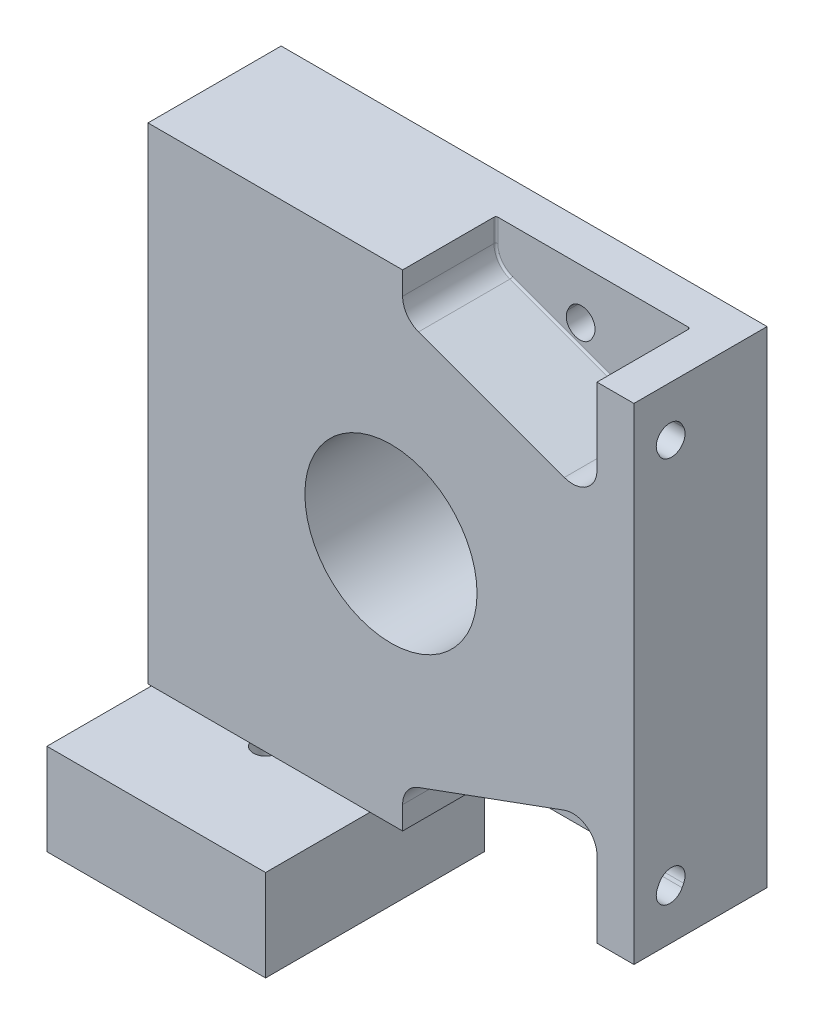
from build123d import *

# Parameters (mm, degrees)
SKETCH2_W                        = 127
SKETCH2_H                        = 127
HOUSING_DEPTH                    = 39.5
SKETCH4_OUTSIDE_W                = 165.78
SKETCH4_OUTSIDE_H                = 165.78
SKETCH4_OUTSIDE_R                = 45.974
CUT_EXTRUDE2_DEPTH               = 4.698
MOUNTING_POCKETS_DEPTH           = 24.384
ENG_METRIC_SLOT_VERTICAL_REACH   = 129
ENG_METRIC_SLOT_HORIZONTAL_DEPTH = 40.5
FILLET3_R                        = 0.508
SKETCH213_W                      = 57.15
SKETCH213_H                      = 57.15
EXTRUDE1_DEPTH                   = 26.924
SKETCH214_R                      = 23.8125
CUT_EXTRUDE3_DEPTH               = 5
SKETCH215_R                      = 3.175
CUT_EXTRUDE4_DEPTH               = 21.924
CUT_EXTRUDE5_REACH               = 131.159
SKETCH216_W                      = 42.545
SKETCH216_H                      = 3.048
F_8_32_TAPPED_HOLE1_D            = 3.4544
F_8_32_TAPPED_HOLE1_DEPTH        = 10.7086
F_8_32_TAPPED_HOLE1_TIP          = 1.037806461
SKETCH241_R                      = 45.974
CUT_EXTRUDE7_DEPTH               = 4.698
SKETCH3_R                        = 22.5
CUT_EXTRUDE8_DEPTH               = 49.26


with BuildPart() as part:
    # Sketch2 → HOUSING (new body)
    with BuildSketch(Plane.XY):
        Rectangle(SKETCH2_W, SKETCH2_H)
    extrude(amount=HOUSING_DEPTH)

    # Sketch4 outside → Cut-Extrude2 (cut)
    with BuildSketch(Plane.XY.offset(39.5)):
        Rectangle(SKETCH4_OUTSIDE_W, SKETCH4_OUTSIDE_H)
        Circle(SKETCH4_OUTSIDE_R, mode=Mode.SUBTRACT)
    extrude(amount=-CUT_EXTRUDE2_DEPTH, mode=Mode.SUBTRACT)

    # Sketch8 → MOUNTING POCKETS (cut)
    with BuildSketch(Plane.XY.offset(34.802)):
        with BuildLine():
            Line((3.048, -63.5), (3.048, -57.528018122))
            ThreePointArc((3.048, -57.528018122), (4.194729662, -53.888172274), (7.220748912, -51.562946647))
            Line((7.220748912, -51.562946647), (45.320748912, -37.656446647))
            ThreePointArc((45.320748912, -37.656446647), (51.137845848, -38.418247784), (53.848, -43.621518122))
            Line((53.848, -43.621518122), (53.848, -63.5))
            Line((53.848, -63.5), (3.048, -63.5))
        make_face()
        with BuildLine():
            Line((3.048, 63.5), (53.848, 63.5))
            Line((53.848, 63.5), (53.848, 43.621518122))
            ThreePointArc((53.848, 43.621518122), (51.137845848, 38.418247784), (45.320748912, 37.656446647))
            Line((45.320748912, 37.656446647), (7.220748912, 51.562946647))
            ThreePointArc((7.220748912, 51.562946647), (4.194729662, 53.888172274), (3.048, 57.528018122))
            Line((3.048, 57.528018122), (3.048, 63.5))
        make_face()
    extrude(amount=-MOUNTING_POCKETS_DEPTH, mode=Mode.SUBTRACT)

    # Sketch21 → ENG_METRIC SLOT VERTICAL (cut, up to next)
    with BuildSketch(Plane(origin=(63.5, -23.646142673, 1.166551585), x_dir=(0, 0, -1), z_dir=(1, 0, 0)), mode=Mode.PRIVATE) as eng_metric_slot_vertical_sk1:
        with BuildLine():
            Line((-20.641506099, 75.242113831), (-21.041506099, 76.042113831))
            ThreePointArc((-21.041506099, 76.042113831), (-25.829419573, 77.63808499), (-27.425390732, 72.850171515))
            Line((-27.425390732, 72.850171515), (-27.025390732, 72.050171515))
            ThreePointArc((-27.025390732, 72.050171515), (-22.237477257, 70.454200357), (-20.641506099, 75.242113831))
        make_face()
    eng_metric_slot_vertical_tool1 = extrude(eng_metric_slot_vertical_sk1.sketch, amount=-ENG_METRIC_SLOT_VERTICAL_REACH, mode=Mode.PRIVATE) & part.part
    add(eng_metric_slot_vertical_tool1.solids().sort_by_distance((63.5, 50.4, 25.2))[0], mode=Mode.SUBTRACT)
    # Sketch21 → ENG_METRIC SLOT VERTICAL (cut, up to next)
    with BuildSketch(Plane(origin=(63.5, -23.646142673, 1.166551585), x_dir=(0, 0, -1), z_dir=(1, 0, 0)), mode=Mode.PRIVATE) as eng_metric_slot_vertical_sk2:
        with BuildLine():
            Line((-27.025390732, -24.757886169), (-27.425390732, -25.557886169))
            ThreePointArc((-27.425390732, -25.557886169), (-25.829419573, -30.345799643), (-21.041506099, -28.749828485))
            Line((-21.041506099, -28.749828485), (-20.641506099, -27.949828485))
            ThreePointArc((-20.641506099, -27.949828485), (-22.237477257, -23.16191501), (-27.025390732, -24.757886169))
        make_face()
    eng_metric_slot_vertical_tool2 = extrude(eng_metric_slot_vertical_sk2.sketch, amount=-ENG_METRIC_SLOT_VERTICAL_REACH, mode=Mode.PRIVATE) & part.part
    add(eng_metric_slot_vertical_tool2.solids().sort_by_distance((63.5, -50.4, 25.2))[0], mode=Mode.SUBTRACT)

    # Sketch212 → ENG_METRIC SLOT HORIZONTAL (cut, through all)
    with BuildSketch(Plane(origin=(34.062086582, -104.655987826, 0), x_dir=(-1, 0, 0), z_dir=(0, 0, -1))):
        with BuildLine():
            Line((12.254028899, 156.251958985), (11.854028899, 157.051958985))
            ThreePointArc((11.854028899, 157.051958985), (7.066115424, 158.647930143), (5.470144266, 153.860016668))
            Line((5.470144266, 153.860016668), (5.870144266, 153.060016668))
            ThreePointArc((5.870144266, 153.060016668), (10.658057741, 151.46404551), (12.254028899, 156.251958985))
        make_face()
        with BuildLine():
            Line((5.870144266, 56.251958985), (5.470144266, 55.451958985))
            ThreePointArc((5.470144266, 55.451958985), (7.066115424, 50.66404551), (11.854028899, 52.260016668))
            Line((11.854028899, 52.260016668), (12.254028899, 53.060016668))
            ThreePointArc((12.254028899, 53.060016668), (10.658057741, 57.847930143), (5.870144266, 56.251958985))
        make_face()
    extrude(amount=-ENG_METRIC_SLOT_HORIZONTAL_DEPTH, mode=Mode.SUBTRACT)

    # Fillet3
    fillet3_edges = [part.edges().sort_by_distance(p)[0] for p in [
        (3.048, -60.514009061, 10.418),
        (4.194729662, -53.888172274, 10.418),
        (26.270748912, -44.609696647, 10.418),
        (51.137845848, -38.418247784, 10.418),
        (53.848, -53.560759061, 10.418),
        (51.137845848, 38.418247784, 10.418),
        (26.270748912, 44.609696647, 10.418),
        (4.194729662, 53.888172274, 10.418),
        (3.048, 60.514009061, 10.418),
        (53.848, 53.560759061, 10.418),
    ]]
    fillet(fillet3_edges, radius=FILLET3_R)

    # Sketch213 → Extrude1 (add)
    with BuildSketch(Plane.XZ.offset(63.5)):
        with Locations((-37.084, 30.48)):
            Rectangle(SKETCH213_W, SKETCH213_H)
    extrude(amount=EXTRUDE1_DEPTH)

    # Sketch214 → Cut-Extrude3 (cut)
    with BuildSketch(Plane.XZ.offset(90.424)):
        with Locations((-37.084, 30.48)):
            Circle(SKETCH214_R)
    extrude(amount=-CUT_EXTRUDE3_DEPTH, mode=Mode.SUBTRACT)

    # Sketch215 → Cut-Extrude4 (cut)
    with BuildSketch(Plane.XZ.offset(85.424)):
        with Locations((-37.084, 30.48)):
            Circle(SKETCH215_R)
    extrude(amount=-CUT_EXTRUDE4_DEPTH, mode=Mode.SUBTRACT)

    # Sketch216 → Cut-Extrude5 (cut, up to next)
    with BuildSketch(Plane.ZY.offset(65.659), mode=Mode.PRIVATE) as cut_extrude5_sk1:
        with Locations((37.7825, -65.024)):
            Rectangle(SKETCH216_W, SKETCH216_H)
    cut_extrude5_tool1 = extrude(cut_extrude5_sk1.sketch, amount=-CUT_EXTRUDE5_REACH, mode=Mode.PRIVATE) & part.part
    add(cut_extrude5_tool1.solids().sort_by_distance((-65.659, -65.024, 37.7825))[0], mode=Mode.SUBTRACT)

    # 8-32 Tapped Hole1
    with Locations(Plane.XZ.offset(90.424)):
        with Locations((-60.706, 6.858), (-60.706, 54.102), (-13.462, 54.102), (-13.462, 6.858)):
            Hole(F_8_32_TAPPED_HOLE1_D / 2, depth=F_8_32_TAPPED_HOLE1_DEPTH)
            with Locations((0, 0, -(F_8_32_TAPPED_HOLE1_DEPTH + F_8_32_TAPPED_HOLE1_TIP / 2))):  # 118° drill point
                Cone(0, F_8_32_TAPPED_HOLE1_D / 2, F_8_32_TAPPED_HOLE1_TIP, mode=Mode.SUBTRACT)

    # Sketch241 → Cut-Extrude7 (cut)
    with BuildSketch(Plane.XY.offset(39.5)):
        Circle(SKETCH241_R)
    extrude(amount=-CUT_EXTRUDE7_DEPTH, mode=Mode.SUBTRACT)

    # Sketch3 → Cut-Extrude8 (cut, through all)
    with BuildSketch(Plane.XY.offset(48.26)):
        Circle(SKETCH3_R)
    extrude(amount=-CUT_EXTRUDE8_DEPTH, mode=Mode.SUBTRACT)


solid = part.part
